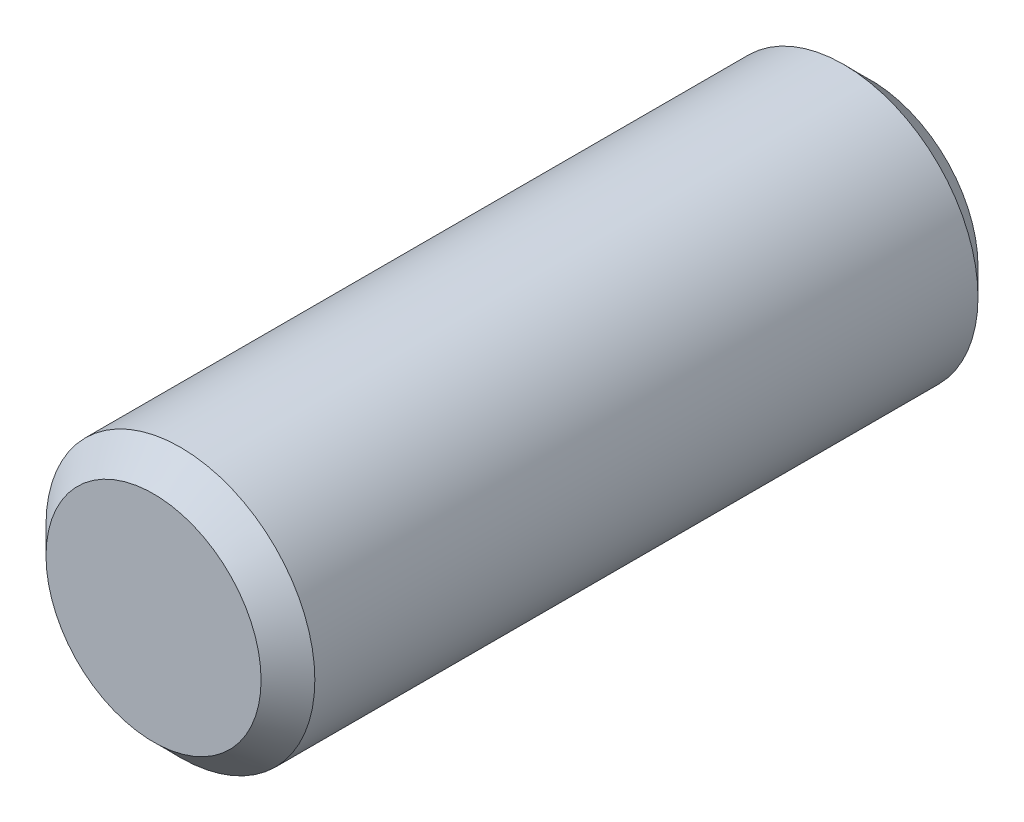
from build123d import *

# Parameters (mm, degrees)
SKETCH_1_R      = 1.5
EXTRUDE_1_DEPTH = 8
CHAMFER_1_SIZE  = 0.3


with BuildPart() as part:
    # 草图1 → 凸台-拉伸1 (new body)
    with BuildSketch(Plane.XY):
        Circle(SKETCH_1_R)
    extrude(amount=EXTRUDE_1_DEPTH)

    # 倒角1
    chamfer_1_edges = [part.edges().sort_by_distance(p)[0] for p in [
        (-1.5, 0, 0),
        (-1.5, 0, 8),
    ]]
    chamfer(chamfer_1_edges, length=CHAMFER_1_SIZE)


solid = part.part
